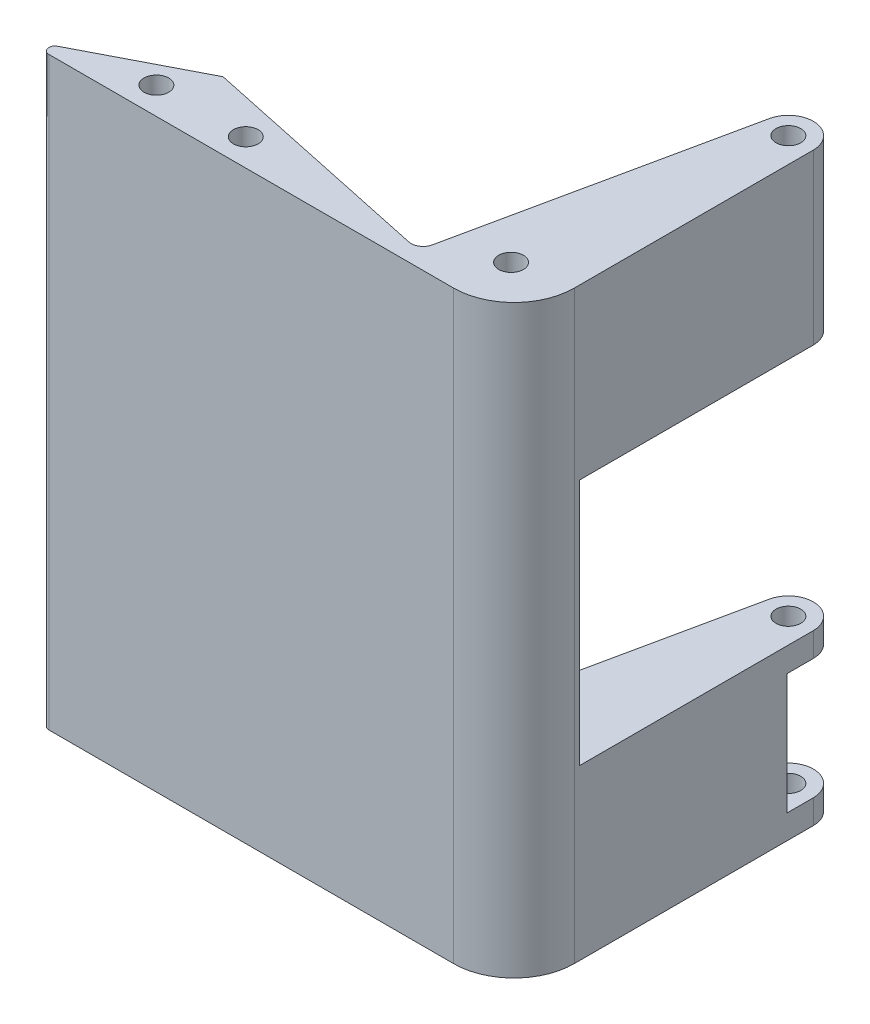
from build123d import *

# Parameters (mm, degrees)
BOSS_EXTRUDE1_DEPTH     = 97
SKETCH2_R               = 2.05
CUT_EXTRUDE1_DEPTH      = 98
SKETCH5_W               = 41.197318768
SKETCH5_H               = 41
CUT_EXTRUDE2_DEPTH      = 60.079477801
CUT_EXTRUDE2_DEPTH_BACK = 29.495236192
CUT_EXTRUDE4_START      = -4
SKETCH6_R               = 2.05
CUT_EXTRUDE4_DEPTH      = 20


with BuildPart() as part:
    # Sketch1 → Boss-Extrude1 (new body)
    with BuildSketch(Plane(origin=(0, 0, 0), x_dir=(1, 0, 0), z_dir=(0, 1, 0))):
        with BuildLine():
            Line((-1.956295201, 0.415823382), (-41.082199231, 8.732291014))
            Line((-41.082199231, 8.732291014), (-58, 0))
            Line((-58, 0), (-59.184498234, -0.611390536))
            ThreePointArc((-59.184498234, -0.611390536), (-59.697587059, -1.73599845), (-58.725833628, -2.5))
            Line((-58.725833628, -2.5), (7.92143542, -2.5))
            Line((7.92143542, -2.5), (8.377039367, -2.5))
            ThreePointArc((8.377039367, -2.5), (15.448107179, 0.428932188), (18.377039367, 7.5))
            Line((18.377039367, 7.5), (18.377039367, 47.131925559))
            ThreePointArc((18.377039367, 47.131925559), (14.674810753, 51.243366322), (10.199141157, 47.990855979))
            Line((10.199141157, 47.990855979), (7.92143542, 37.267423588))
            Line((7.92143542, 37.267423588), (0.415823382, 1.956295201))
            ThreePointArc((0.415823382, 1.956295201), (-0.45119375, 0.694777447), (-1.956295201, 0.415823382))
        make_face()
    extrude(amount=BOSS_EXTRUDE1_DEPTH)

    # Sketch2 → Cut-Extrude1 (cut, through all)
    with BuildSketch(Plane(origin=(0, 97, 0), x_dir=(1, 0, 0), z_dir=(0, 1, 0))):
        with Locations((-45.407004093, 2)):
            Circle(SKETCH2_R)
        with Locations((9.444671894, 5.955813006)):
            Circle(SKETCH2_R)
        with Locations((14.242983228, 47.131925559)):
            Circle(SKETCH2_R)
        with Locations((-30.580095712, 2)):
            Circle(SKETCH2_R)
    extrude(amount=-CUT_EXTRUDE1_DEPTH, mode=Mode.SUBTRACT)

    # Sketch5 → Cut-Extrude2 (cut, two sides)
    with BuildSketch(Plane(origin=(-9.781476007, 0, -2.079116908), x_dir=(-0.207911691, 0, 0.978147601), z_dir=(-0.978147601, 0, -0.207911691))) as cut_extrude2_sk:
        with Locations((-32.598659384, 48.5)):
            Rectangle(SKETCH5_W, SKETCH5_H)
    extrude(amount=CUT_EXTRUDE2_DEPTH, mode=Mode.SUBTRACT)
    extrude(cut_extrude2_sk.sketch, amount=-CUT_EXTRUDE2_DEPTH_BACK, mode=Mode.SUBTRACT)

    # Sketch6 → Cut-Extrude4 (cut)
    with BuildSketch(Plane.XZ.offset(CUT_EXTRUDE4_START)):
        with BuildLine():
            Line((18.377039367, -47.131925559), (18.377039367, -42.783410889))
            ThreePointArc((18.377039367, -42.783410889), (13.61624642, -41.164748591), (9.295652814, -43.737235327))
            Line((9.295652814, -43.737235327), (10.199141157, -47.990855979))
            ThreePointArc((10.199141157, -47.990855979), (14.674810753, -51.243366322), (18.377039367, -47.131925559))
        make_face()
        with Locations((14.242983228, -47.131925559)):
            Circle(SKETCH6_R, mode=Mode.SUBTRACT)
        with BuildLine():
            ThreePointArc((9.295652814, -43.737235327), (12.465904513, -52.862718807), (20.242983228, -47.131925559))
            ThreePointArc((20.242983228, -47.131925559), (19.756799367, -44.765951852), (18.377039367, -42.783410889))
            Line((18.377039367, -42.783410889), (18.377039367, -47.131925559))
            ThreePointArc((18.377039367, -47.131925559), (14.674810753, -51.243366322), (10.199141157, -47.990855979))
            Line((10.199141157, -47.990855979), (9.295652814, -43.737235327))
        make_face()
    extrude(amount=-CUT_EXTRUDE4_DEPTH, mode=Mode.SUBTRACT)


solid = part.part
